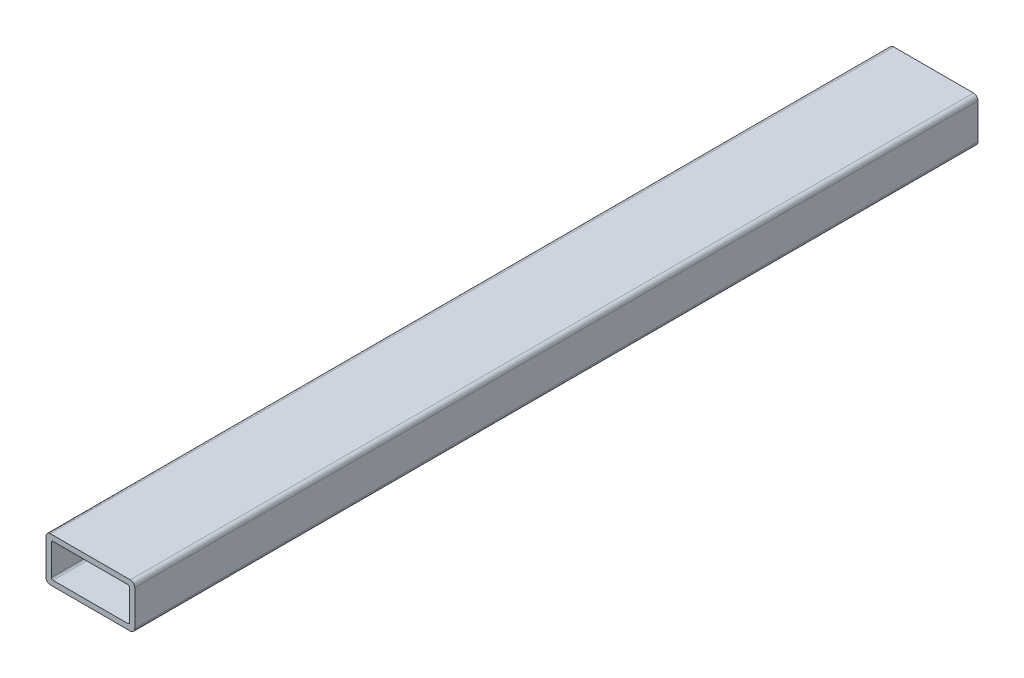
from build123d import *

# Parameters (mm, degrees)
BOSS_EXTRUDE1_DEPTH = 482.6


with BuildPart() as part:
    # Sketch4 → Boss-Extrude1 (new body)
    with BuildSketch(Plane.XY):
        with BuildLine():
            Line((25.4, -10.16), (25.4, 10.16))
            ThreePointArc((25.4, 10.16), (24.656051224, 11.956051224), (22.86, 12.7))
            Line((22.86, 12.7), (-22.86, 12.7))
            ThreePointArc((-22.86, 12.7), (-24.656051224, 11.956051224), (-25.4, 10.16))
            Line((-25.4, 10.16), (-25.4, -10.16))
            ThreePointArc((-25.4, -10.16), (-24.656051224, -11.956051224), (-22.86, -12.7))
            Line((-22.86, -12.7), (22.86, -12.7))
            ThreePointArc((22.86, -12.7), (24.656051224, -11.956051224), (25.4, -10.16))
        make_face()
        with BuildLine():
            Line((22.352, 8.6868), (22.352, -8.6868))
            ThreePointArc((22.352, -8.6868), (22.069299465, -9.369299465), (21.3868, -9.652))
            Line((21.3868, -9.652), (-21.3868, -9.652))
            ThreePointArc((-21.3868, -9.652), (-22.069299465, -9.369299465), (-22.352, -8.6868))
            Line((-22.352, -8.6868), (-22.352, 8.6868))
            ThreePointArc((-22.352, 8.6868), (-22.069299465, 9.369299465), (-21.3868, 9.652))
            Line((-21.3868, 9.652), (21.3868, 9.652))
            ThreePointArc((21.3868, 9.652), (22.069299465, 9.369299465), (22.352, 8.6868))
        make_face(mode=Mode.SUBTRACT)
    extrude(amount=BOSS_EXTRUDE1_DEPTH)


solid = part.part
